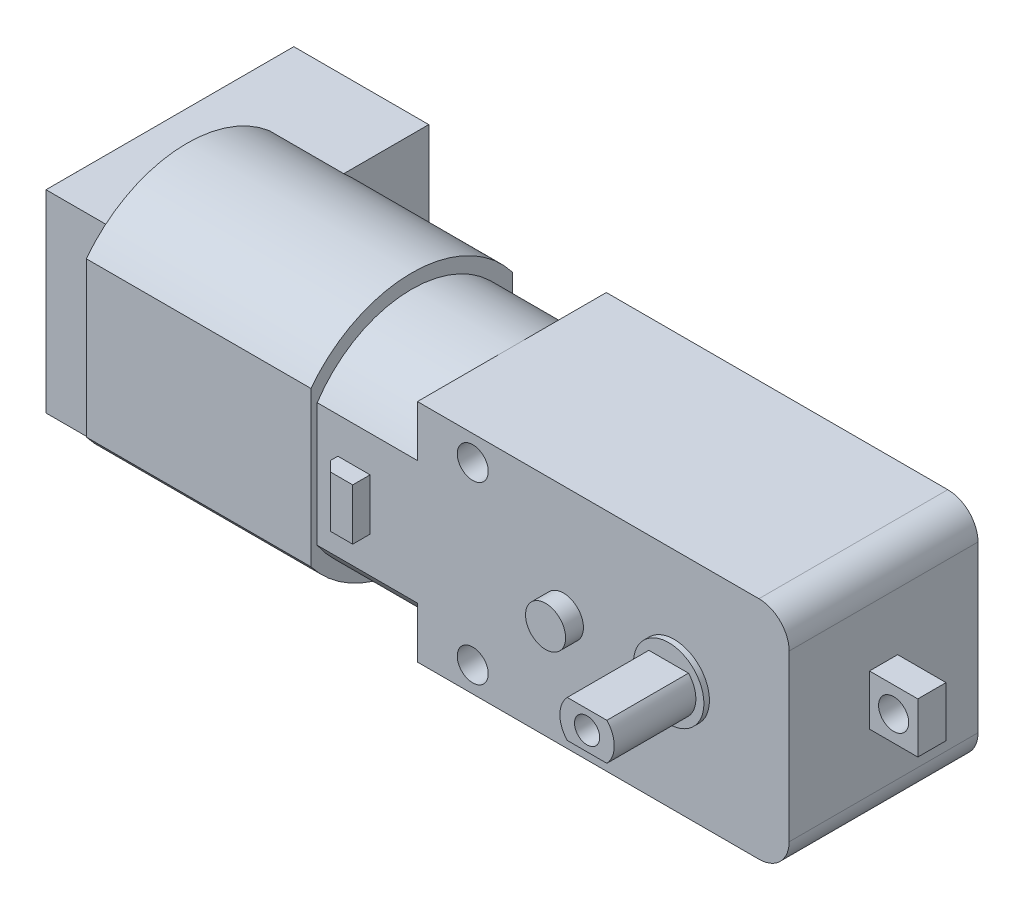
from build123d import *

# Parameters (mm, degrees)
CROQUIS1_W                    = 36.9
CROQUIS1_H                    = 22.4
CROQUIS1_R                    = 2.7
CROQUIS1_R_2                  = 1.99
CROQUIS1_R_3                  = 1.54
SALIENTE_EXTRUIR1_DEPTH       = 9.375
SALIENTE_EXTRUIR2_START       = 9.375
CROQUIS1_3_R                  = 2.7
SALIENTE_EXTRUIR2_DEPTH       = 8.65
SALIENTE_EXTRUIR3_START       = 9.375
CROQUIS1_5_R                  = 1.99
SALIENTE_EXTRUIR3_DEPTH       = 1.77
CROQUIS2_W                    = 8.65
CROQUIS2_H                    = 0.85
CORTAR_EXTRUIR1_DEPTH         = 3.385
CROQUIS1_6_W                  = 4.8
CROQUIS1_6_H                  = 5
CROQUIS1_6_R                  = 1.495
SALIENTE_EXTRUIR4_DEPTH       = 1.4
CROQUIS1_8_W                  = 7.4
CROQUIS1_8_H                  = 9.6
CROQUIS1_8_W_2                = 3.2
CROQUIS1_8_H_2                = 2.55
CROQUIS3_W                    = 22.3
CROQUIS3_H                    = 2.6
CORTAR_EXTRUIR2_DEPTH         = 13.6
CORTAR_EXTRUIR2_DEPTH_BACK    = 13.6
CROQUIS1_10_W                 = 3.2
CROQUIS1_10_H                 = 5.1
SALIENTE_EXTRUIR5_DEPTH       = 11.1
CROQUIS1_11_W                 = 6
CROQUIS1_11_H                 = 19.2
CROQUIS1_11_W_2               = 7.4
CROQUIS1_11_H_2               = 9.6
SALIENTE_EXTRUIR6_DEPTH       = 8
SALIENTE_EXTRUIR6_DEPTH_BACK  = 16.6
TALADRO_ROSCADO_M3X0_51_D     = 2.5
TALADRO_ROSCADO_M3X0_51_DEPTH = 6
TALADRO_ROSCADO_M3X0_51_TIP   = 0.751075774
REDONDEO1_R                   = 3
SALIENTE_EXTRUIR7_START       = 9.375
CROQUIS6_R                    = 3.5
SALIENTE_EXTRUIR7_DEPTH       = 0.55
CHAFL_N1_SIZE                 = 1


with BuildPart() as part:
    # Croquis1 → Saliente-Extruir1 (new body, symmetric)
    with BuildSketch(Plane.XY):
        with Locations((-7.04, 0)):
            Rectangle(CROQUIS1_W, CROQUIS1_H)
        Circle(CROQUIS1_R, mode=Mode.SUBTRACT)
        with Locations((-11, 0)):
            Circle(CROQUIS1_R_2, mode=Mode.SUBTRACT)
        with Locations((-20, 8.7)):
            Circle(CROQUIS1_R_3, mode=Mode.SUBTRACT)
        with Locations((-20, -8.7)):
            Circle(CROQUIS1_R_3, mode=Mode.SUBTRACT)
        Circle(CROQUIS1_R)
        with Locations((-11, 0)):
            Circle(CROQUIS1_R_2)
    extrude(amount=SALIENTE_EXTRUIR1_DEPTH, both=True)

    # Croquis1_3 → Saliente-Extruir2 (add)
    with BuildSketch(Plane.XY.offset(SALIENTE_EXTRUIR2_START)):
        Circle(CROQUIS1_3_R)
    extrude(amount=SALIENTE_EXTRUIR2_DEPTH)

    # Croquis1_5 → Saliente-Extruir3 (add)
    with BuildSketch(Plane.XY.offset(SALIENTE_EXTRUIR3_START)):
        with Locations((-11, 0)):
            Circle(CROQUIS1_5_R)
    extrude(amount=SALIENTE_EXTRUIR3_DEPTH)

    # Croquis2 → Cortar-Extruir1 (cut, symmetric)
    with BuildSketch(Plane(origin=(0, 0, 0), x_dir=(0, 0, -1), z_dir=(1, 0, 0))):
        with Locations((-13.7, 2.275)):
            Rectangle(CROQUIS2_W, CROQUIS2_H)
        with Locations((-13.7, -2.275)):
            Rectangle(CROQUIS2_W, CROQUIS2_H)
    extrude(amount=CORTAR_EXTRUIR1_DEPTH, both=True, mode=Mode.SUBTRACT)

    # Croquis1_6 → Saliente-Extruir4 (add, symmetric)
    with BuildSketch(Plane.XY):
        with Locations((13.81, 0)):
            Rectangle(CROQUIS1_6_W, CROQUIS1_6_H)
        with Locations((13.81, 0)):
            Circle(CROQUIS1_6_R, mode=Mode.SUBTRACT)
    extrude(amount=SALIENTE_EXTRUIR4_DEPTH, both=True)

    # Croquis1_8 → Revoluci_n1 (revolve)
    with BuildSketch(Plane.XY):
        Polygon((-30.19, 0), (-25.49, 0), (-25.49, 11.2), (-35.44, 11.2), (-35.44, 12.6), (-57.74, 12.6), (-57.74, 9.6), (-50.34, 9.6), (-50.34, 0), (-33.39, 0), (-33.39, 2.55), (-30.19, 2.55), align=None)
        with Locations((-54.04, 4.8)):
            Rectangle(CROQUIS1_8_W, CROQUIS1_8_H)
        with Locations((-31.79, 1.275)):
            Rectangle(CROQUIS1_8_W_2, CROQUIS1_8_H_2)
    revolve(axis=Axis((-25.49, 0, 0), (-1, 0, 0)))

    # Croquis3 → Cortar-Extruir2 (cut, two sides)
    with BuildSketch(Plane(origin=(0, 0, 0), x_dir=(1, 0, 0), z_dir=(0, 1, 0))) as cortar_extruir2_sk:
        Polygon((-35.44, 10), (-35.44, 9.375), (-25.49, 9.375), (-25.49, 11.2), (-35.44, 11.2), align=None)
        with Locations((-46.59, 11.3)):
            Rectangle(CROQUIS3_W, CROQUIS3_H)
        with Locations((-46.59, -11.3)):
            Rectangle(CROQUIS3_W, CROQUIS3_H)
        Polygon((-25.49, -9.375), (-35.44, -9.375), (-35.44, -10), (-35.44, -11.2), (-25.49, -11.2), align=None)
    extrude(amount=CORTAR_EXTRUIR2_DEPTH, mode=Mode.SUBTRACT)
    extrude(cortar_extruir2_sk.sketch, amount=-CORTAR_EXTRUIR2_DEPTH_BACK, mode=Mode.SUBTRACT)

    # Croquis1_10 → Saliente-Extruir5 (add, symmetric)
    with BuildSketch(Plane.XY):
        with Locations((-31.79, 0)):
            Rectangle(CROQUIS1_10_W, CROQUIS1_10_H)
    extrude(amount=SALIENTE_EXTRUIR5_DEPTH, both=True)

    # Croquis1_11 → Saliente-Extruir6 (add, two sides)
    with BuildSketch(Plane.XY) as saliente_extruir6_sk:
        with Locations((-60.74, 0)):
            Rectangle(CROQUIS1_11_W, CROQUIS1_11_H)
        with Locations((-54.04, 4.8)):
            Rectangle(CROQUIS1_11_W_2, CROQUIS1_11_H_2)
        with Locations((-54.04, -4.8)):
            Rectangle(CROQUIS1_11_W_2, CROQUIS1_11_H_2)
    extrude(amount=SALIENTE_EXTRUIR6_DEPTH)
    extrude(saliente_extruir6_sk.sketch, amount=-SALIENTE_EXTRUIR6_DEPTH_BACK)

    # Taladro roscado M3x0.51
    with Locations(Plane.XY.offset(18.025)):
        with Locations((0, 0)):
            Hole(TALADRO_ROSCADO_M3X0_51_D / 2, depth=TALADRO_ROSCADO_M3X0_51_DEPTH)
            with Locations((0, 0, -(TALADRO_ROSCADO_M3X0_51_DEPTH + TALADRO_ROSCADO_M3X0_51_TIP / 2))):  # 118° drill point
                Cone(0, TALADRO_ROSCADO_M3X0_51_D / 2, TALADRO_ROSCADO_M3X0_51_TIP, mode=Mode.SUBTRACT)

    # Redondeo1
    redondeo1_edges = [part.edges().sort_by_distance(p)[0] for p in [
        (11.41, 11.2, 0),
        (11.41, -11.2, 0),
    ]]
    fillet(redondeo1_edges, radius=REDONDEO1_R)

    # Croquis6 → Saliente-Extruir7 (add)
    with BuildSketch(Plane.XY.offset(SALIENTE_EXTRUIR7_START)):
        Circle(CROQUIS6_R)
    extrude(amount=SALIENTE_EXTRUIR7_DEPTH)

    # Chafl_n1
    chafl_n1_edges = [part.edges().sort_by_distance(p)[0] for p in [
        (-33.39, 0, 11.1),
    ]]
    chamfer(chafl_n1_edges, length=CHAFL_N1_SIZE)


solid = part.part
